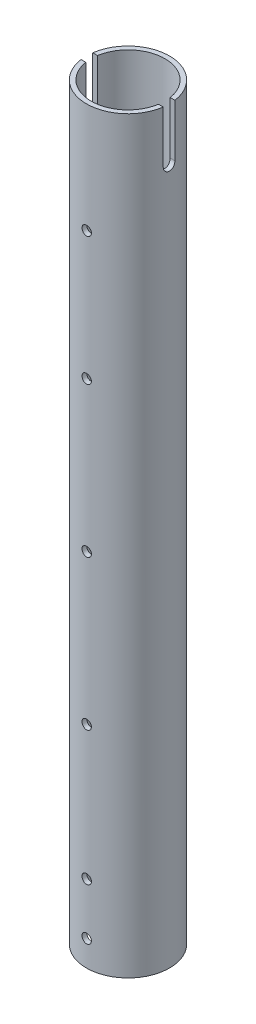
from build123d import *

# Parameters (mm, degrees)
SKETCH1_R           = 28.178125
SKETCH1_R_2         = 25.003125
BOSS_EXTRUDE1_DEPTH = 508
SKETCH3_R           = 3.175
CUT_EXTRUDE1_DEPTH  = 57.35625
SKETCH4_R           = 3.175
CUT_EXTRUDE2_DEPTH  = 60.452
CUT_EXTRUDE3_DEPTH  = 57.3562501


with BuildPart() as part:
    # Sketch1 → Boss-Extrude1 (new body)
    with BuildSketch(Plane(origin=(0, 0, 0), x_dir=(1, 0, 0), z_dir=(0, 1, 0))):
        Circle(SKETCH1_R)
        Circle(SKETCH1_R_2, mode=Mode.SUBTRACT)
    extrude(amount=BOSS_EXTRUDE1_DEPTH)

    # Sketch3 → Cut-Extrude1 (cut, through all)
    with BuildSketch(Plane.XY.offset(28.178125)):
        with Locations((0, 17.4625)):
            Circle(SKETCH3_R)
        with Locations((0, 52.3875)):
            Circle(SKETCH3_R)
    extrude(amount=-CUT_EXTRUDE1_DEPTH, mode=Mode.SUBTRACT)

    # Sketch4 → Cut-Extrude2 (cut, symmetric)
    with BuildSketch(Plane.XY):
        with Locations((0, 143.256)):
            Circle(SKETCH4_R)
        with Locations((0, 244.856)):
            Circle(SKETCH4_R)
        with Locations((0, 346.456)):
            Circle(SKETCH4_R)
        with Locations((0, 433.530922765)):
            Circle(SKETCH4_R)
    extrude(amount=CUT_EXTRUDE2_DEPTH, both=True, mode=Mode.SUBTRACT)

    # Sketch6 → Cut-Extrude3 (cut, through all)
    with BuildSketch(Plane(origin=(28.178125, 0, 0), x_dir=(0, 0, -1), z_dir=(1, 0, 0))):
        with BuildLine():
            Line((3.96875, 508), (3.96875, 472.44))
            ThreePointArc((3.96875, 472.44), (0, 468.47125), (-3.96875, 472.44))
            Line((-3.96875, 472.44), (-3.96875, 508))
            ThreePointArc((-3.96875, 508), (0, 511.96875), (3.96875, 508))
        make_face()
    extrude(amount=-CUT_EXTRUDE3_DEPTH, mode=Mode.SUBTRACT)


solid = part.part
